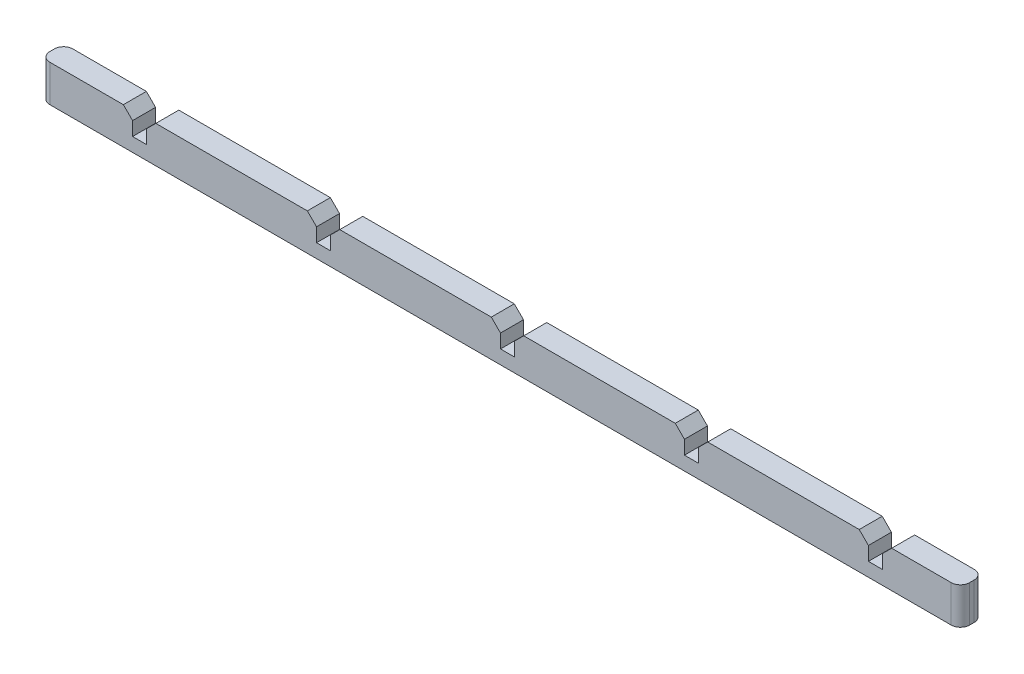
from build123d import *

# Parameters (mm, degrees)
SKETCH1_W           = 200
SKETCH1_H           = 5
BOSS_EXTRUDE1_DEPTH = 8
SKETCH2_W           = 3.05
SKETCH2_H           = 5
CUT_EXTRUDE1_DEPTH  = 5
CHAMFER1_SIZE       = 2
FILLET1_R           = 2


with BuildPart() as part:
    # Sketch1 → Boss-Extrude1 (new body)
    with BuildSketch(Plane(origin=(0, 0, 0), x_dir=(1, 0, 0), z_dir=(0, 1, 0))):
        Rectangle(SKETCH1_W, SKETCH1_H)
    extrude(amount=BOSS_EXTRUDE1_DEPTH)

    # Sketch2 → Cut-Extrude1 (cut)
    with BuildSketch(Plane(origin=(0, 8, 0), x_dir=(1, 0, 0), z_dir=(0, 1, 0))):
        with Locations((-78.475, 0)):
            Rectangle(SKETCH2_W, SKETCH2_H)
        with Locations((-38.475, 0)):
            Rectangle(SKETCH2_W, SKETCH2_H)
        with Locations((1.525, 0)):
            Rectangle(SKETCH2_W, SKETCH2_H)
        with Locations((41.525, 0)):
            Rectangle(SKETCH2_W, SKETCH2_H)
        with Locations((81.525, 0)):
            Rectangle(SKETCH2_W, SKETCH2_H)
    extrude(amount=-CUT_EXTRUDE1_DEPTH, mode=Mode.SUBTRACT)

    # Chamfer1
    chamfer1_edges = [part.edges().sort_by_distance(p)[0] for p in [
        (-80, 8, 0),
        (-76.95, 8, 0),
        (-40, 8, 0),
        (-36.95, 8, 0),
        (0, 8, 0),
        (3.05, 8, 0),
        (40, 8, 0),
        (43.05, 8, 0),
        (80, 8, 0),
        (83.05, 8, 0),
    ]]
    chamfer(chamfer1_edges, length=CHAMFER1_SIZE)

    # Fillet1
    fillet1_edges = [part.edges().sort_by_distance(p)[0] for p in [
        (100, 4, 2.5),
        (-100, 4, 2.5),
        (-100, 4, -2.5),
        (100, 4, -2.5),
    ]]
    fillet(fillet1_edges, radius=FILLET1_R)


solid = part.part
